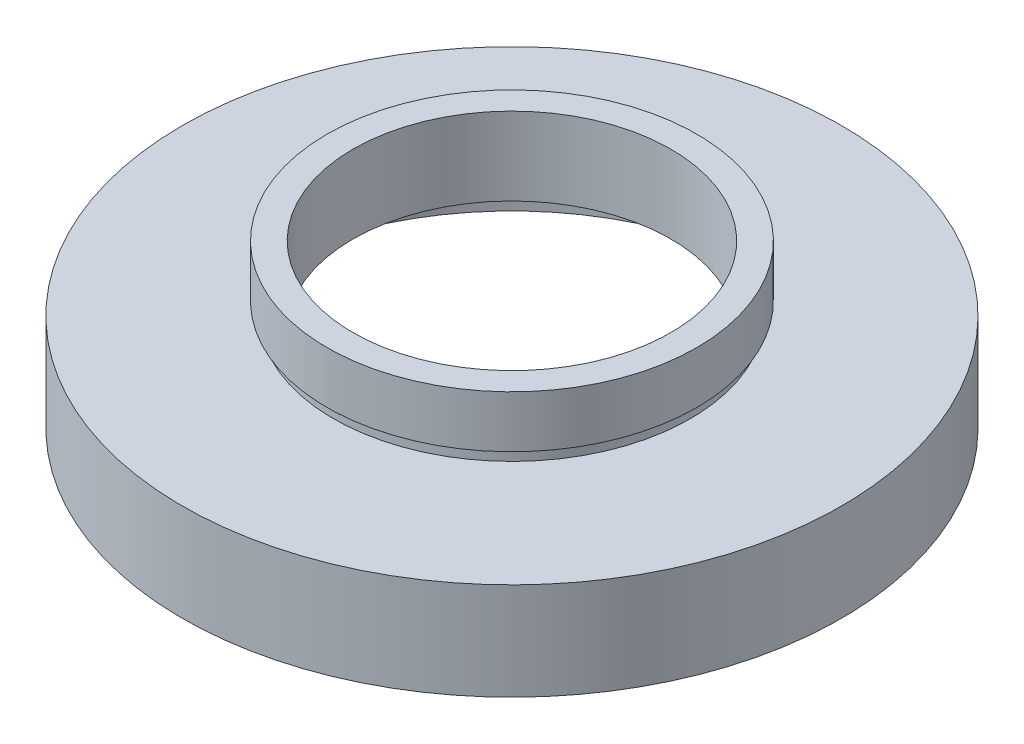
from build123d import *


with BuildPart() as part:
    # 草图1 → 旋转1 (revolve)
    with BuildSketch(Plane.XY, mode=Mode.PRIVATE) as revolve_1_sk:
        Polygon((20.5, 0), (20.5, 5.5), (21.1, 5.5), (21.1, 6.5), (12.25, 6.5), (12.25, 12.5), (14.25, 12.5), (14.25, 8.5), (13.75, 8.5), (13.75, 7.5), (25.4, 7.5), (25.4, 0), align=None)
    revolve(revolve_1_sk.sketch.rotate(Axis((0, 16.886018237, 0), (0, -1, 0)), 180), axis=Axis((0, 16.886018237, 0), (0, -1, 0)))  # turned: the seam where the file's is


solid = part.part
